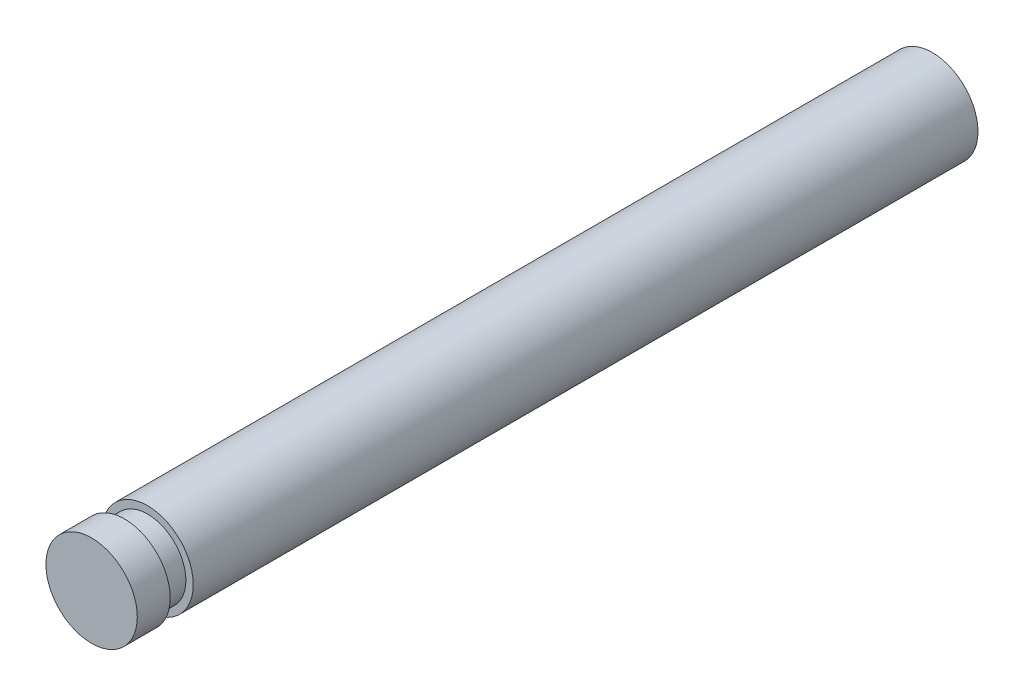
from build123d import *

# Parameters (mm, degrees)
SKETCH1_R           = 3.175
BOSS_EXTRUDE1_DEPTH = 54.5338
SKETCH2_R           = 2.667
BOSS_EXTRUDE2_DEPTH = 1.6002
SKETCH3_R           = 3.175
BOSS_EXTRUDE3_DEPTH = 2.286


with BuildPart() as part:
    # Sketch1 → Boss-Extrude1 (new body)
    with BuildSketch(Plane.XY):
        Circle(SKETCH1_R)
    extrude(amount=-BOSS_EXTRUDE1_DEPTH)

    # Sketch2 → Boss-Extrude2 (add)
    with BuildSketch(Plane.XY):
        Circle(SKETCH2_R)
    extrude(amount=BOSS_EXTRUDE2_DEPTH)

    # Sketch3 → Boss-Extrude3 (add)
    with BuildSketch(Plane.XY.offset(1.6002)):
        Circle(SKETCH3_R)
    extrude(amount=BOSS_EXTRUDE3_DEPTH)


solid = part.part
